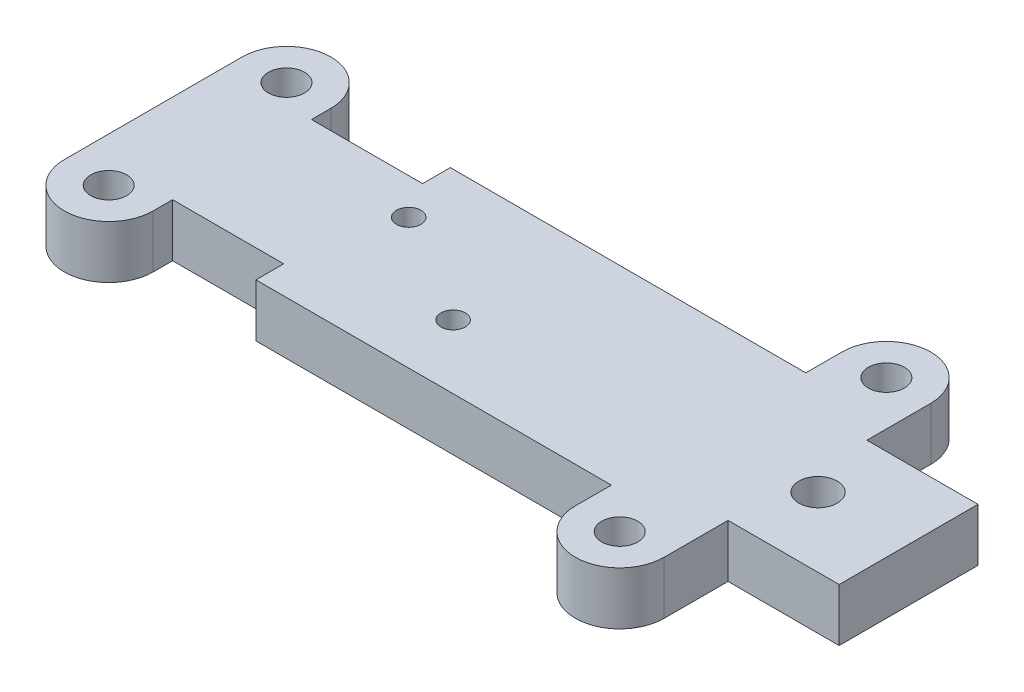
from build123d import *

# Parameters (mm, degrees)
SKETCH1_R                 = 1.625
BOSS_EXTRUDE1_DEPTH       = 4.7625
SKETCH6_R                 = 1.1
CUT_EXTRUDE3_DEPTH        = 5.7625
F_8_32_TAPPED_HOLE1_D     = 3.4544
F_8_32_TAPPED_HOLE1_DEPTH = 12.29
F_8_32_TAPPED_HOLE1_TIP   = 1.037806461


with BuildPart() as part:
    # Sketch1 → Boss-Extrude1 (new body)
    with BuildSketch(Plane(origin=(0, 0, 0), x_dir=(1, 0, 0), z_dir=(0, 1, 0))):
        with BuildLine():
            Line((-17, 6.25), (-17, 8))
            ThreePointArc((-17, 8), (-21, 12), (-25, 8))
            Line((-25, 8), (-25, 0))
            Line((-25, 0), (43, 0))
            Line((43, 0), (43, 6.25))
            Line((43, 6.25), (33, 6.25))
            Line((33, 6.25), (33, 12))
            ThreePointArc((33, 12), (29, 16), (25, 12))
            Line((25, 12), (25, 8.75))
            Line((25, 8.75), (-7, 8.75))
            Line((-7, 8.75), (-7, 6.25))
            Line((-7, 6.25), (-17, 6.25))
        make_face()
        with Locations((-21, 8)):
            Circle(SKETCH1_R, mode=Mode.SUBTRACT)
        with Locations((29, 12)):
            Circle(SKETCH1_R, mode=Mode.SUBTRACT)
    boss_extrude1 = extrude(amount=BOSS_EXTRUDE1_DEPTH)

    # Mirror1: Boss-Extrude1 across plane
    add(boss_extrude1.mirror(Plane.XY))

    # Sketch6 → Cut-Extrude3 (cut, through all)
    with BuildSketch(Plane(origin=(0, 4.7625, 0), x_dir=(1, 0, 0), z_dir=(0, 1, 0))):
        with Locations((5, -3)):
            Circle(SKETCH6_R)
        with Locations((-5, 3)):
            Circle(SKETCH6_R)
    extrude(amount=-CUT_EXTRUDE3_DEPTH, mode=Mode.SUBTRACT)

    # #8-32 Tapped Hole1
    with Locations(Plane(origin=(0, 4.7625, 0), x_dir=(-1, 0, 0), z_dir=(0, 1, 0))):
        with Locations((-34.85, 0)):
            Hole(F_8_32_TAPPED_HOLE1_D / 2, depth=F_8_32_TAPPED_HOLE1_DEPTH)
            with Locations((0, 0, -(F_8_32_TAPPED_HOLE1_DEPTH + F_8_32_TAPPED_HOLE1_TIP / 2))):  # 118° drill point
                Cone(0, F_8_32_TAPPED_HOLE1_D / 2, F_8_32_TAPPED_HOLE1_TIP, mode=Mode.SUBTRACT)


solid = part.part
